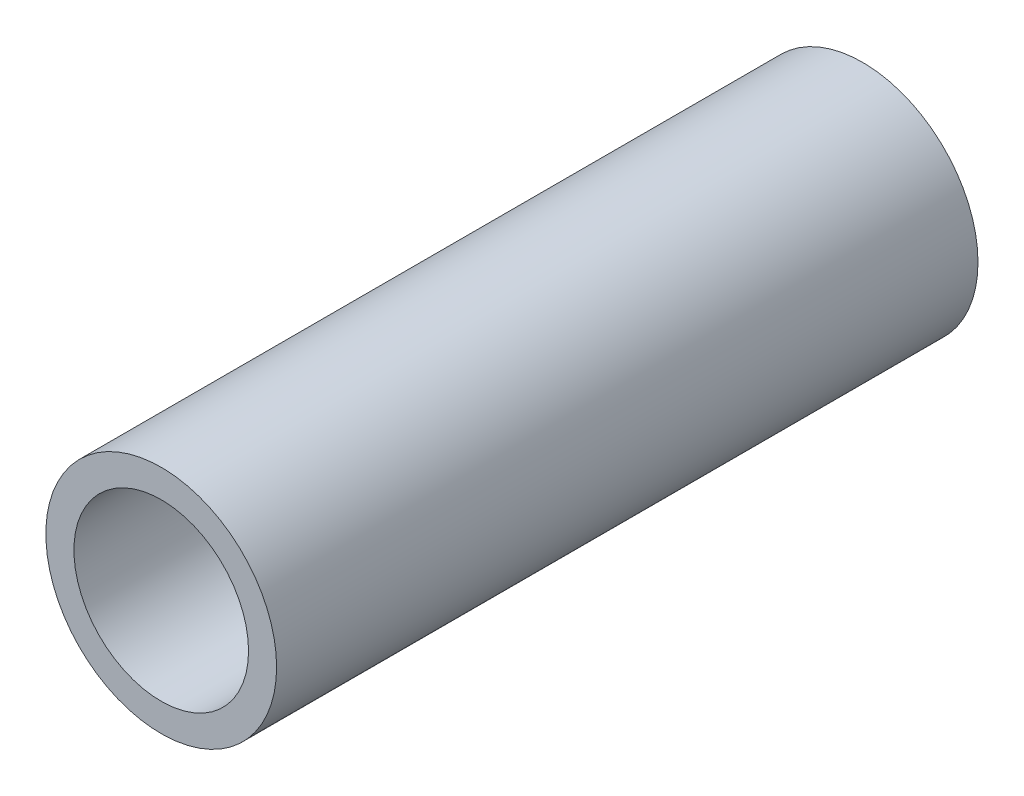
from build123d import *

# Parameters (mm, degrees)
SKETCH1_R           = 16.45
SKETCH1_R_2         = 12.45
BOSS_EXTRUDE1_DEPTH = 50


with BuildPart() as part:
    # Sketch1 → Boss-Extrude1 (new body, symmetric)
    with BuildSketch(Plane.XY):
        Circle(SKETCH1_R)
        Circle(SKETCH1_R_2, mode=Mode.SUBTRACT)
    extrude(amount=BOSS_EXTRUDE1_DEPTH, both=True)


solid = part.part
